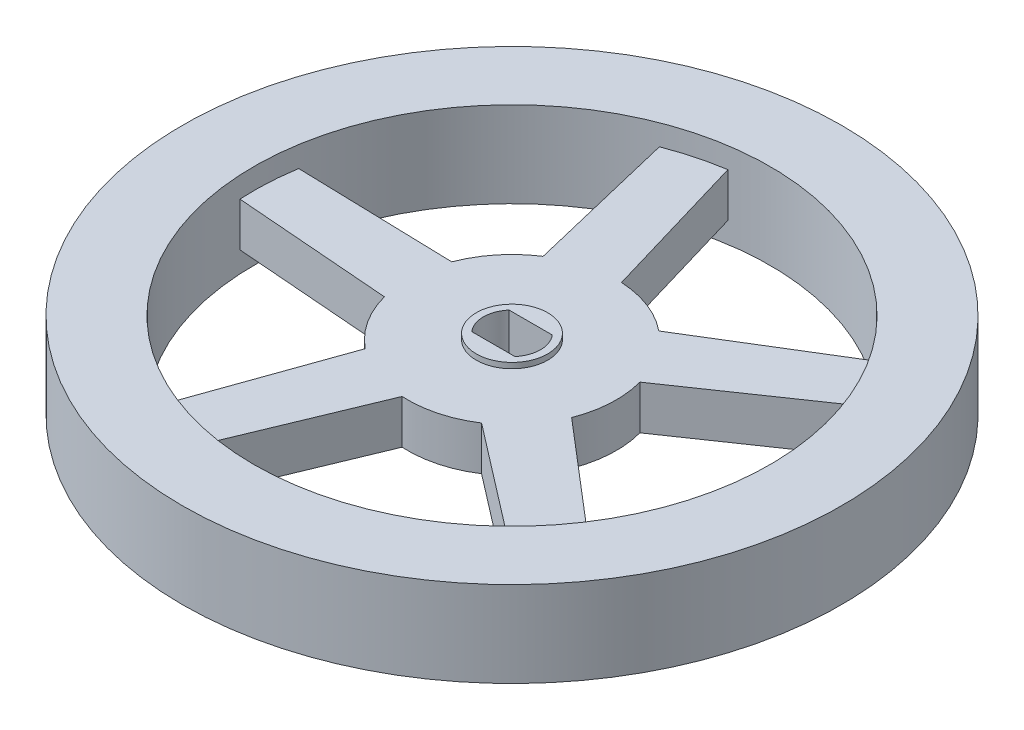
from build123d import *

# Parameters (mm, degrees)
SKETCH1_R                = 3.25
BOSS_EXTRUDE1_DEPTH      = 4
SKETCH1_4_R              = 3.25
BOSS_EXTRUDE2_DEPTH      = 4.5
SKETCH1_5_R              = 1
BOSS_EXTRUDE3_DEPTH      = 0.5
BOSS_EXTRUDE4_DEPTH      = 5.9
BOSS_EXTRUDE4_DEPTH_BACK = 1.9
SKETCH1_6_R              = 30


with BuildPart() as part:
    # Sketch1 → Boss-Extrude1 (new body)
    with BuildSketch(Plane(origin=(0, 0, 0), x_dir=(1, 0, 0), z_dir=(0, 1, 0))):
        with BuildLine():
            Line((-8.492467394, 21.911823237), (-5.150259407, 7.982783226))
            ThreePointArc((-5.150259407, 7.982783226), (-7.379213612, 5.983076673), (-8.874983612, 3.388903346))
            Line((-8.874983612, 3.388903346), (-23.194055647, 3.779653774))
            ThreePointArc((-23.194055647, 3.779653774), (-23.46703432, 1.244307122), (-23.463699022, -1.305690697))
            Line((-23.463699022, -1.305690697), (-9.183595688, -2.431372091))
            ThreePointArc((-9.183595688, -2.431372091), (-7.970546468, -5.16917682), (-5.965559371, -7.39338227))
            Line((-5.965559371, -7.39338227), (-10.762021714, -20.890880513))
            ThreePointArc((-10.762021714, -20.890880513), (-8.435118809, -21.933963861), (-6.008896103, -22.718784466))
            Line((-6.008896103, -22.718784466), (-0.525514867, -9.485453818))
            ThreePointArc((-0.525514867, -9.485453818), (2.453144985, -9.177803642), (5.188065158, -7.958264881))
            Line((5.188065158, -7.958264881), (16.54276044, -16.690927986))
            ThreePointArc((16.54276044, -16.690927986), (18.253844197, -14.800242296), (19.749996995, -12.735290287))
            Line((19.749996995, -12.735290287), (8.858809639, -3.430960767))
            ThreePointArc((8.858809639, -3.430960767), (9.486673449, -0.503017773), (9.171959975, 2.474904082))
            Line((9.171959975, 2.474904082), (20.986009934, 10.575319714))
            ThreePointArc((20.986009934, 10.575319714), (19.716614948, 12.78691108), (18.215065524, 14.847942212))
            Line((18.215065524, 14.847942212), (6.000560323, 7.365003449))
            ThreePointArc((6.000560323, 7.365003449), (3.409941646, 8.866921561), (0.48051785, 9.487839722))
            Line((0.48051785, 9.487839722), (-3.572693012, 23.226835011))
            ThreePointArc((-3.572693012, 23.226835011), (-6.068306016, 22.702987955), (-8.492467394, 21.911823237))
        make_face()
        Circle(SKETCH1_R, mode=Mode.SUBTRACT)
    extrude(amount=BOSS_EXTRUDE1_DEPTH)

    # Sketch1_4 → Boss-Extrude2 (add)
    with BuildSketch(Plane(origin=(0, 0, 0), x_dir=(1, 0, 0), z_dir=(0, 1, 0))):
        Circle(SKETCH1_4_R)
        with BuildLine():
            Line((-1.967231557, 1.7), (1.967231557, 1.7))
            ThreePointArc((1.967231557, 1.7), (2.6, 0), (1.967231557, -1.7))
            Line((1.967231557, -1.7), (-1.967231557, -1.7))
            ThreePointArc((-1.967231557, -1.7), (-2.6, 0), (-1.967231557, 1.7))
        make_face(mode=Mode.SUBTRACT)
    extrude(amount=BOSS_EXTRUDE2_DEPTH)

    # Sketch1_5 → Boss-Extrude3 (add)
    with BuildSketch(Plane(origin=(0, 0, 0), x_dir=(1, 0, 0), z_dir=(0, 1, 0))):
        with BuildLine():
            Line((1.967231557, 1.7), (-1.967231557, 1.7))
            ThreePointArc((-1.967231557, 1.7), (-2.6, 0), (-1.967231557, -1.7))
            Line((-1.967231557, -1.7), (1.967231557, -1.7))
            ThreePointArc((1.967231557, -1.7), (2.6, 0), (1.967231557, 1.7))
        make_face()
        Circle(SKETCH1_5_R, mode=Mode.SUBTRACT)
    extrude(amount=BOSS_EXTRUDE3_DEPTH)

    # Sketch1_6 → Boss-Extrude4 (add, two sides: drawn at the far end of the back side and taken through both)
    with BuildSketch(Plane(origin=(0, 0, 0), x_dir=(1, 0, 0), z_dir=(0, 1, 0)).offset(-BOSS_EXTRUDE4_DEPTH_BACK)):
        Circle(SKETCH1_6_R)
        with BuildLine():
            ThreePointArc((-8.492467394, 21.911823237), (-7.291125837, 22.340310741), (-6.068306016, 22.702987955))
            ThreePointArc((-6.068306016, 22.702987955), (-4.827610123, 22.998786501), (-3.572693012, 23.226835011))
            ThreePointArc((-3.572693012, 23.226835011), (8.435118809, 21.933963861), (18.215065524, 14.847942212))
            ThreePointArc((18.215065524, 14.847942212), (19.716614948, 12.78691108), (20.986009934, 10.575319714))
            ThreePointArc((20.986009934, 10.575319714), (22.862865453, 5.435014561), (23.5, 0))
            ThreePointArc((23.5, 0), (22.543013656, -6.637961683), (19.749996995, -12.735290287))
            ThreePointArc((19.749996995, -12.735290287), (18.253844197, -14.800242296), (16.54276044, -16.690927986))
            ThreePointArc((16.54276044, -16.690927986), (6.068306016, -22.702987955), (-6.008896103, -22.718784466))
            ThreePointArc((-6.008896103, -22.718784466), (-8.435118809, -21.933963861), (-10.762021714, -20.890880513))
            ThreePointArc((-10.762021714, -20.890880513), (-19.716614948, -12.78691108), (-23.463699022, -1.305690697))
            ThreePointArc((-23.463699022, -1.305690697), (-23.46703432, 1.244307122), (-23.194055647, 3.779653774))
            ThreePointArc((-23.194055647, 3.779653774), (-18.253844197, 14.800242296), (-8.492467394, 21.911823237))
        make_face(mode=Mode.SUBTRACT)
    extrude(amount=BOSS_EXTRUDE4_DEPTH + BOSS_EXTRUDE4_DEPTH_BACK)


solid = part.part
